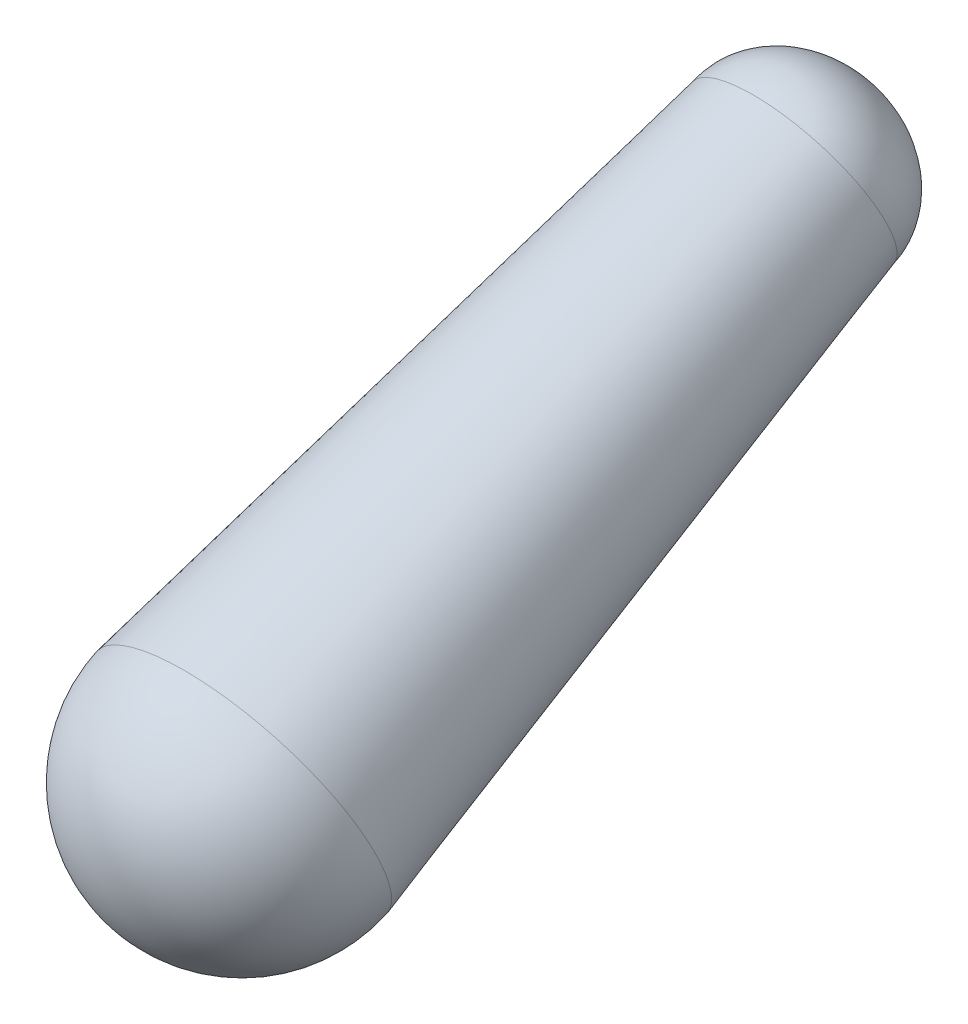
from build123d import *

# Parameters (mm, degrees)
SKETCH1_R           = 10
BOSS_EXTRUDE1_DEPTH = 43.840424
BOSS_EXTRUDE1_DRAFT = -4
DOME1_FACE_RADIUS   = 10
DOME1_HEIGHT        = 10
DOME2_FACE_RADIUS   = 6.934378915
DOME2_HEIGHT        = 6


with BuildPart() as part:
    # Sketch1 → Boss-Extrude1 (with draft: the straight prism first)
    with BuildSketch(Plane(origin=(0, -69.944427944, -149.45909702), x_dir=(1, 0, 0), z_dir=(0, -0.4162480648879251, 0.909251092095609))):
        Circle(SKETCH1_R)
    extrude(amount=-BOSS_EXTRUDE1_DEPTH)
    # Boss-Extrude1: the draft: its side faces are tilted about the plane it starts from
    boss_extrude1_sides = [part.faces().sort_by_distance(p)[0] for p in [
        (-10, -60.820182117, -169.39007372),
    ]]
    draft(boss_extrude1_sides, Plane(origin=(0, -69.944427944, -149.45909702), x_dir=(1, 0, 0), z_dir=(0, -0.4162480648879251, 0.909251092095609)), BOSS_EXTRUDE1_DRAFT)

    # Dome1: a dome of height H over a round flat face of radius A is a cap of a sphere of radius (A * A + H * H) / (2 * H)
    dome1_r = (DOME1_FACE_RADIUS * DOME1_FACE_RADIUS + DOME1_HEIGHT * DOME1_HEIGHT) / (2 * DOME1_HEIGHT)
    dome1_base = Plane((0, -69.944427944, -149.45909702), z_dir=(0, -0.416248064888, 0.909251092096))
    with Locations(dome1_base.offset(DOME1_HEIGHT - dome1_r)):
        dome1_ball = Sphere(dome1_r, mode=Mode.PRIVATE)
    add(split(dome1_ball, bisect_by=dome1_base, keep=Keep.TOP, mode=Mode.PRIVATE))

    # Dome2: an elliptical dome of height H over a round flat face of radius A is half a spheroid: the quarter ellipse of half axes A and H revolved about the face's axis
    with BuildSketch(Plane((0, -51.69593629, -189.32105042), x_dir=(0, -0.9092510920956485, -0.41624806488783905), z_dir=(1, 0, 0)), mode=Mode.PRIVATE) as dome2_quarter:
        Ellipse(DOME2_FACE_RADIUS, DOME2_HEIGHT)
        Rectangle(DOME2_FACE_RADIUS, DOME2_HEIGHT, align=(Align.MIN, Align.MIN), mode=Mode.INTERSECT)
    revolve(dome2_quarter.sketch, axis=Axis((0, -51.69593629, -189.32105042), (0, 0.416248064888, -0.909251092096)))


solid = part.part
